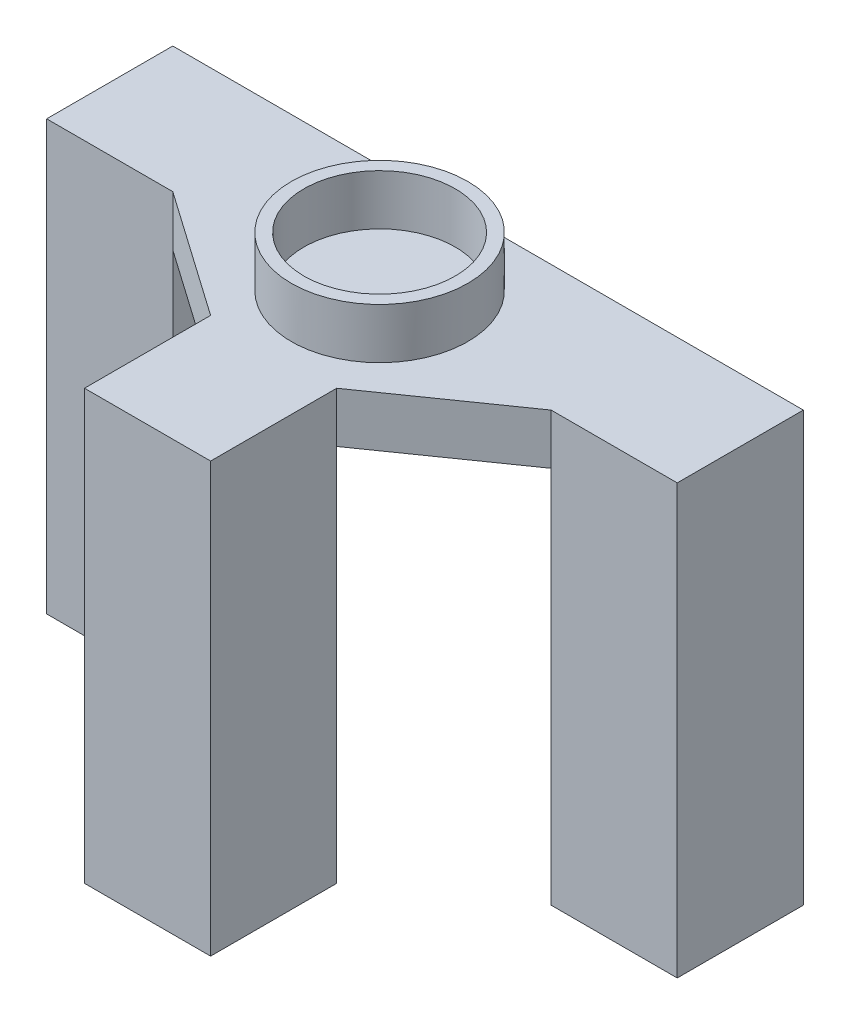
from build123d import *

# Parameters (mm, degrees)
EXTRUDE_1_DEPTH     = 4
SKETCH_1_W          = 10
SKETCH_1_H          = 10
EXTRUDE_2_DEPTH     = 30
SKETCH_6_W          = 10
SKETCH_6_H          = 10
EXTRUDE_4_DEPTH     = 30
SKETCH_9_R          = 7
SKETCH_9_R_2        = 6
EXTRUDE_5_DEPTH     = 4
SKETCH_11_R         = 4
CUT_EXTRUDE_1_DEPTH = 30


with BuildPart() as part:
    # 草图2 → 凸台-拉伸1 (new body)
    with BuildSketch(Plane(origin=(0, 0, 0), x_dir=(1, 0, 0), z_dir=(0, 1, 0))):
        Polygon((-5, -22), (5, -22), (5, -12), (15, -5), (25, -5), (25, 5), (-25, 5), (-25, -5), (-15, -5), (-5, -12), align=None)
    extrude(amount=EXTRUDE_1_DEPTH)

    # 草图1 → 凸台-拉伸2 (add)
    with BuildSketch(Plane(origin=(0, 0, 0), x_dir=(1, 0, 0), z_dir=(0, 1, 0))):
        with Locations((-20, 0)):
            Rectangle(SKETCH_1_W, SKETCH_1_H)
        with Locations((20, 0)):
            Rectangle(SKETCH_1_W, SKETCH_1_H)
    extrude(amount=-EXTRUDE_2_DEPTH)

    # 草图6 → 凸台-拉伸4 (add)
    with BuildSketch(Plane.XZ):
        with Locations((0, 17)):
            Rectangle(SKETCH_6_W, SKETCH_6_H)
    extrude(amount=EXTRUDE_4_DEPTH)

    # 草图9 → 凸台-拉伸5 (add)
    with BuildSketch(Plane(origin=(0, 4, 0), x_dir=(1, 0, 0), z_dir=(0, 1, 0))):
        with Locations((0, -3.6)):
            Circle(SKETCH_9_R)
        with Locations((0, -3.6)):
            Circle(SKETCH_9_R_2, mode=Mode.SUBTRACT)
    extrude(amount=EXTRUDE_5_DEPTH)

    # 草图11 → 切除-拉伸1 (cut)
    with BuildSketch(Plane.XZ.offset(30)):
        with Locations((0, 17)):
            Circle(SKETCH_11_R)
        with Locations((20, 0)):
            Circle(SKETCH_11_R)
        with Locations((-20, 0)):
            Circle(SKETCH_11_R)
    extrude(amount=-CUT_EXTRUDE_1_DEPTH, mode=Mode.SUBTRACT)


solid = part.part
